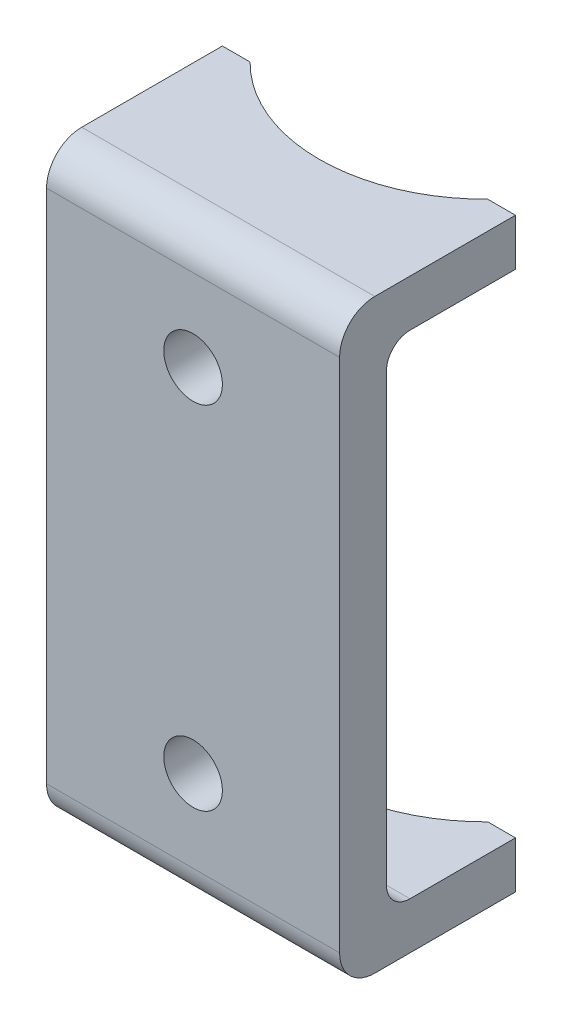
from build123d import *

# Parameters (mm, degrees)
BOSS_EXTRUDE3_DEPTH     = 12.5
SKETCH2_R               = 2.5
CUT_EXTRUDE3_DEPTH      = 4
SKETCH3_R               = 14.238624177
CUT_EXTRUDE4_DEPTH      = 26
CUT_EXTRUDE4_DEPTH_BACK = 26


with BuildPart() as part:
    # Sketch1 → Boss-Extrude3 (new body, symmetric)
    with BuildSketch(Plane(origin=(0, 0, 0), x_dir=(0, 0, -1), z_dir=(1, 0, 0))):
        with BuildLine():
            Line((0, 22), (0, -22))
            ThreePointArc((0, -22), (0.878679656, -24.121320344), (3, -25))
            Line((3, -25), (15, -25))
            Line((15, -25), (15, -21))
            Line((15, -21), (6, -21))
            ThreePointArc((6, -21), (4.585786438, -20.414213562), (4, -19))
            Line((4, -19), (4, 19))
            ThreePointArc((4, 19), (4.585786438, 20.414213562), (6, 21))
            Line((6, 21), (15, 21))
            Line((15, 21), (15, 25))
            Line((15, 25), (3, 25))
            ThreePointArc((3, 25), (0.878679656, 24.121320344), (0, 22))
        make_face()
    extrude(amount=BOSS_EXTRUDE3_DEPTH, both=True)

    # Sketch2 → Cut-Extrude3 (cut)
    with BuildSketch(Plane.XY):
        with Locations((0, 15)):
            Circle(SKETCH2_R)
        with Locations((0, -15)):
            Circle(SKETCH2_R)
    extrude(amount=-CUT_EXTRUDE3_DEPTH, mode=Mode.SUBTRACT)

    # Sketch3 → Cut-Extrude4 (cut, two sides)
    with BuildSketch(Plane(origin=(0, 0, 0), x_dir=(1, 0, 0), z_dir=(0, 1, 0))) as cut_extrude4_sk:
        with Locations((0, 25)):
            Circle(SKETCH3_R)
    extrude(amount=CUT_EXTRUDE4_DEPTH, mode=Mode.SUBTRACT)
    extrude(cut_extrude4_sk.sketch, amount=-CUT_EXTRUDE4_DEPTH_BACK, mode=Mode.SUBTRACT)


solid = part.part
